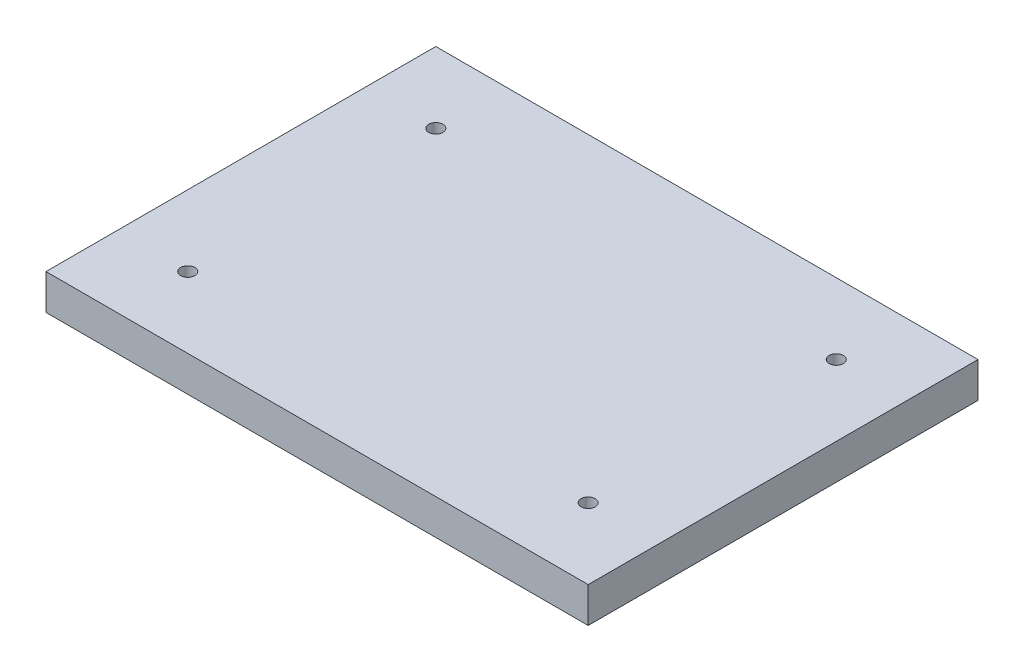
from build123d import *

# Parameters (mm, degrees)
SKETCH1_W           = 153
SKETCH1_H           = 110
SKETCH1_R           = 2
BOSS_EXTRUDE1_DEPTH = 10


with BuildPart() as part:
    # Sketch1 → Boss-Extrude1 (new body)
    with BuildSketch(Plane(origin=(0, 0, 0), x_dir=(1, 0, 0), z_dir=(0, 1, 0))):
        with Locations((178.5, 70)):
            Rectangle(SKETCH1_W, SKETCH1_H)
        with Locations((122, 35)):
            Circle(SKETCH1_R, mode=Mode.SUBTRACT)
        with Locations((235, 35)):
            Circle(SKETCH1_R, mode=Mode.SUBTRACT)
        with Locations((235, 105)):
            Circle(SKETCH1_R, mode=Mode.SUBTRACT)
        with Locations((122, 105)):
            Circle(SKETCH1_R, mode=Mode.SUBTRACT)
    extrude(amount=BOSS_EXTRUDE1_DEPTH)


solid = part.part
